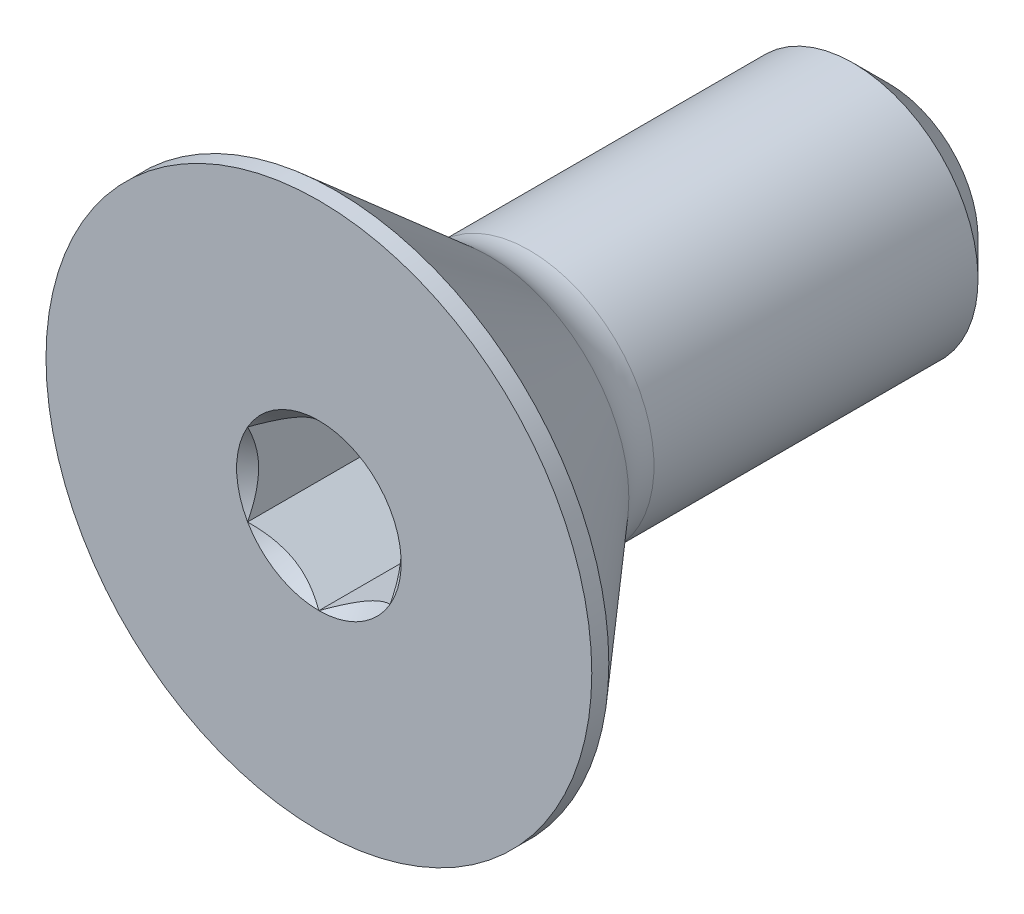
from build123d import *

# Parameters (mm, degrees)
SKETCH1_W          = 9.525
SKETCH1_H          = 2.0828
CHAMFER1_SIZE      = 0.5953125
CUT_EXTRUDE2_DEPTH = 1.99136


with BuildPart() as part:
    # Sketch1 → Revolve1 (revolve)
    with BuildSketch(Plane(origin=(0, 0, 0), x_dir=(0, 0, -1), z_dir=(1, 0, 0))):
        with Locations((4.7625, 1.0414)):
            Rectangle(SKETCH1_W, SKETCH1_H)
    revolve(axis=Axis((0, 0, -9.525), (0, 0, 1)))

    # Chamfer1
    chamfer1_edges = [part.edges().sort_by_distance(p)[0] for p in [
        (0, -2.0828, -9.525),
    ]]
    chamfer(chamfer1_edges, length=CHAMFER1_SIZE)

    # Sketch7 → Revolve2 (revolve)
    with BuildSketch(Plane(origin=(0, 0, 0), x_dir=(0, 0, -1), z_dir=(1, 0, 0)), mode=Mode.PRIVATE) as revolve2_sk:
        with BuildLine():
            Line((0, 4.5593), (0.28448, 4.5593))
            Line((0.28448, 4.5593), (2.8448, 2.333647779))
            ThreePointArc((2.8448, 2.333647779), (3.157581097, 2.147562581), (3.515722863, 2.0828))
            Line((3.515722863, 2.0828), (3.515722863, 0))
            Line((3.515722863, 0), (0, 0))
            Line((0, 0), (0, 4.5593))
        make_face()
    revolve(revolve2_sk.sketch.rotate(Axis((0, 0, 0), (0, 0, -1)), 180), axis=Axis((0, 0, 0), (0, 0, -1)))

    # Boss-Extrude1 cone 1 section (through the dimple's axis) → Boss-Extrude1 (revolve)
    with BuildSketch(Plane(origin=(0, 0, -3.515722863), x_dir=(0, -1, 0), z_dir=(1, 0, 0))):
        Polygon((0, 0), (2.0828, 0), (0, 2.0828), align=None)
    revolve(axis=Axis((0, 0, -3.515722863), (0, 0, -1)))

    # Sketch5 → Cut-Extrude2 (cut)
    with BuildSketch(Plane.XY):
        Polygon((1.190625, -0.687407664), (1.190625, 0.687407664), (0, 1.374815329), (-1.190625, 0.687407664), (-1.190625, -0.687407664), (0, -1.374815329), align=None)
    extrude(amount=-CUT_EXTRUDE2_DEPTH, mode=Mode.SUBTRACT)

    # Cut-Extrude3 cone 1 section (through the dimple's axis) → Cut-Extrude3 (revolve, cut)
    with BuildSketch(Plane(origin=(0, 0, 0), x_dir=(0, -1, 0), z_dir=(1, 0, 0))):
        Polygon((0, 0), (1.374815329, 0), (0, 1.374815329), align=None)
    revolve(axis=Axis((0, 0, 0), (0, 0, -1)), mode=Mode.SUBTRACT)


solid = part.part
